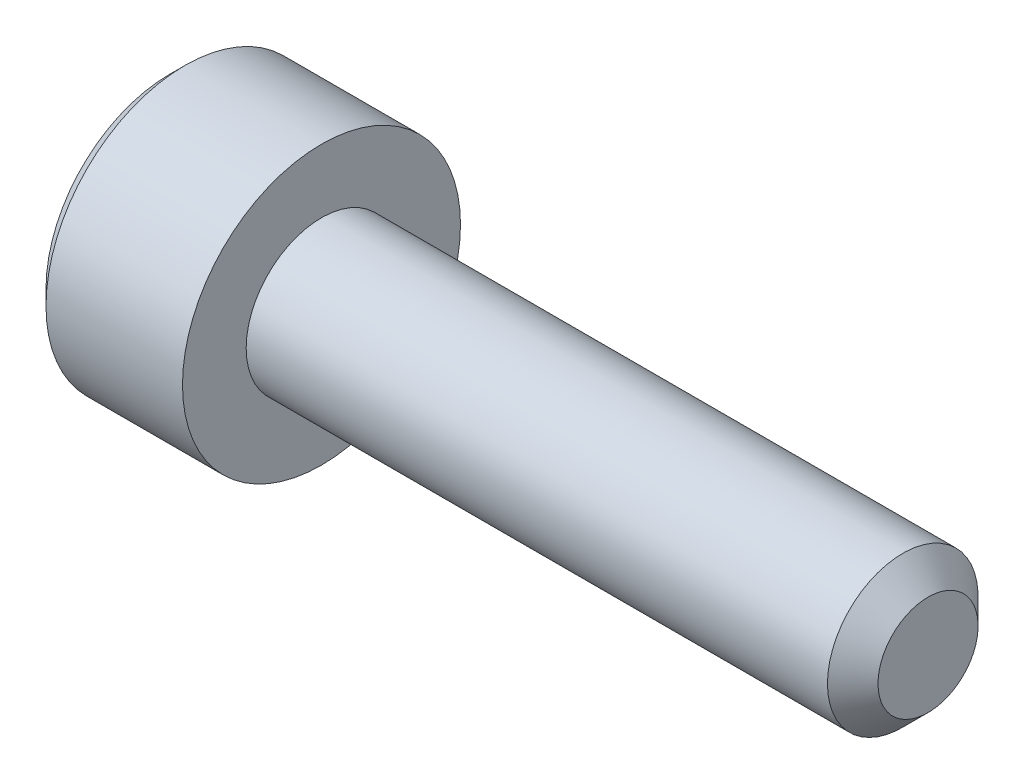
from build123d import *

# Parameters (mm, degrees)
CHAMFER1_SIZE      = 0.5
CHAMFER2_SIZE      = 0.3
CUT_EXTRUDE1_DEPTH = 2.5
CHAMFER3_SIZE      = 0.3


with BuildPart() as part:
    # Sketch1 → Revolve1 (revolve)
    with BuildSketch(Plane.XY):
        Polygon((0, 0), (0, 2.75), (3, 2.75), (3, 1.49), (15, 1.49), (15, 0), align=None)
    revolve(axis=Axis((-88.705490849, 0, 0), (1, 0, 0)))

    # Chamfer1
    chamfer1_edges = [part.edges().sort_by_distance(p)[0] for p in [
        (15, -1.49, 0),
    ]]
    chamfer(chamfer1_edges, length=CHAMFER1_SIZE)

    # Chamfer2
    chamfer2_edges = [part.edges().sort_by_distance(p)[0] for p in [
        (0, -2.75, 0),
    ]]
    chamfer(chamfer2_edges, length=CHAMFER2_SIZE)

    # Sketch3 → Cut-Extrude1 (cut)
    with BuildSketch(Plane(origin=(0, 0, 0), x_dir=(0, 0, -1), z_dir=(1, 0, 0))):
        Polygon((-1.443375673, 0), (-0.721687836, -1.25), (0.721687836, -1.25), (1.443375673, 0), (0.721687836, 1.25), (-0.721687836, 1.25), align=None)
    extrude(amount=CUT_EXTRUDE1_DEPTH, mode=Mode.SUBTRACT)

    # Chamfer3
    chamfer3_edges = [part.edges().sort_by_distance(p)[0] for p in [
        (0, 1.25, 0),
        (0, 0.625, 1.082531755),
        (0, -0.625, 1.082531755),
        (0, -1.25, 0),
        (0, -0.625, -1.082531755),
        (0, 0.625, -1.082531755),
    ]]
    chamfer(chamfer3_edges, length=CHAMFER3_SIZE)


solid = part.part
